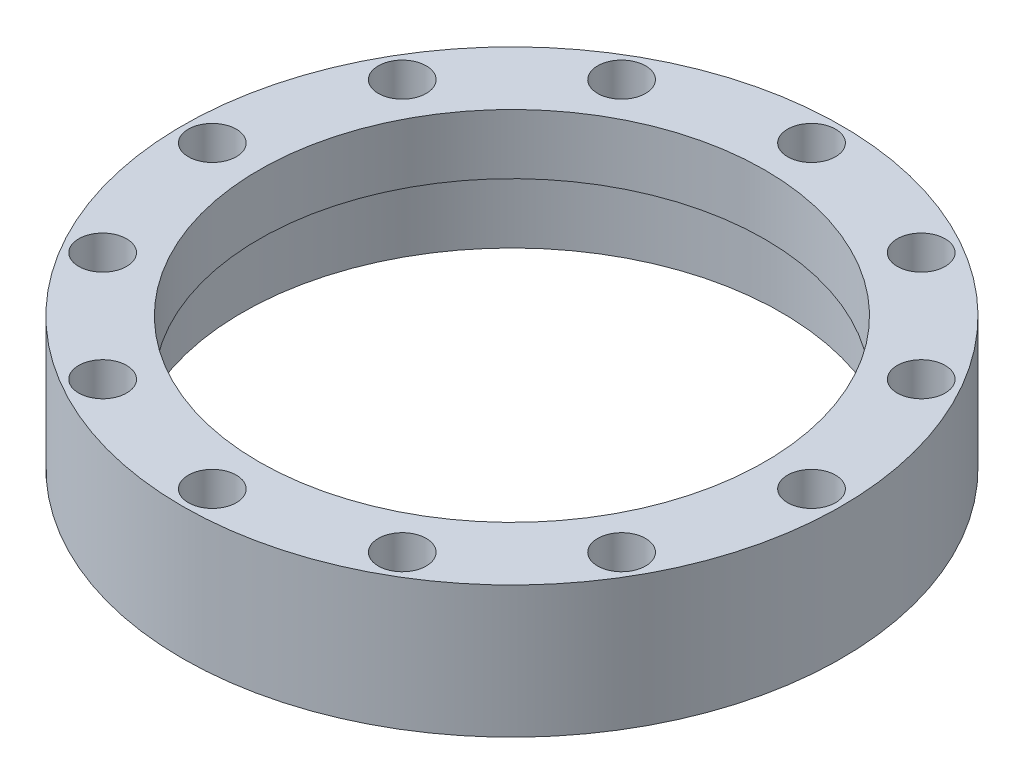
from build123d import *

# Parameters (mm, degrees)
SKETCH1_R           = 27.5
SKETCH1_R_2         = 22.5
SKETCH1_R_3         = 1.6
BOSS_EXTRUDE1_DEPTH = 11
SKETCH2_R           = 22.5
SKETCH2_R_2         = 21.1
BOSS_EXTRUDE2_DEPTH = 5
SKETCH3_R           = 2
CUT_EXTRUDE1_DEPTH  = 5


with BuildPart() as part:
    # Sketch1 → Boss-Extrude1 (new body)
    with BuildSketch(Plane(origin=(0, 0, 0), x_dir=(1, 0, 0), z_dir=(0, 1, 0))):
        Circle(SKETCH1_R)
        Circle(SKETCH1_R_2, mode=Mode.SUBTRACT)
        with Locations((0, 25)):
            Circle(SKETCH1_R_3, mode=Mode.SUBTRACT)
        with Locations((12.5, 21.650635095)):
            Circle(SKETCH1_R_3, mode=Mode.SUBTRACT)
        with Locations((21.650635095, 12.5)):
            Circle(SKETCH1_R_3, mode=Mode.SUBTRACT)
        with Locations((25, 0)):
            Circle(SKETCH1_R_3, mode=Mode.SUBTRACT)
        with Locations((21.650635095, -12.5)):
            Circle(SKETCH1_R_3, mode=Mode.SUBTRACT)
        with Locations((12.5, -21.650635095)):
            Circle(SKETCH1_R_3, mode=Mode.SUBTRACT)
        with Locations((0, -25)):
            Circle(SKETCH1_R_3, mode=Mode.SUBTRACT)
        with Locations((-12.5, -21.650635095)):
            Circle(SKETCH1_R_3, mode=Mode.SUBTRACT)
        with Locations((-21.650635095, -12.5)):
            Circle(SKETCH1_R_3, mode=Mode.SUBTRACT)
        with Locations((-25, 0)):
            Circle(SKETCH1_R_3, mode=Mode.SUBTRACT)
        with Locations((-21.650635095, 12.5)):
            Circle(SKETCH1_R_3, mode=Mode.SUBTRACT)
        with Locations((-12.5, 21.650635095)):
            Circle(SKETCH1_R_3, mode=Mode.SUBTRACT)
    extrude(amount=BOSS_EXTRUDE1_DEPTH)

    # Sketch2 → Boss-Extrude2 (add)
    with BuildSketch(Plane(origin=(0, 11, 0), x_dir=(1, 0, 0), z_dir=(0, 1, 0))):
        Circle(SKETCH2_R)
        Circle(SKETCH2_R_2, mode=Mode.SUBTRACT)
    extrude(amount=-BOSS_EXTRUDE2_DEPTH)

    # Sketch3 → Cut-Extrude1 (cut)
    with BuildSketch(Plane(origin=(0, 11, 0), x_dir=(1, 0, 0), z_dir=(0, 1, 0))):
        with Locations((0, 25)):
            Circle(SKETCH3_R)
        with Locations((12.5, 21.650635095)):
            Circle(SKETCH3_R)
        with Locations((21.650635095, 12.5)):
            Circle(SKETCH3_R)
        with Locations((25, 0)):
            Circle(SKETCH3_R)
        with Locations((21.650635095, -12.5)):
            Circle(SKETCH3_R)
        with Locations((12.5, -21.650635095)):
            Circle(SKETCH3_R)
        with Locations((0, -25)):
            Circle(SKETCH3_R)
        with Locations((-12.5, -21.650635095)):
            Circle(SKETCH3_R)
        with Locations((-21.650635095, -12.5)):
            Circle(SKETCH3_R)
        with Locations((-25, 0)):
            Circle(SKETCH3_R)
        with Locations((-21.650635095, 12.5)):
            Circle(SKETCH3_R)
        with Locations((-12.5, 21.650635095)):
            Circle(SKETCH3_R)
    extrude(amount=-CUT_EXTRUDE1_DEPTH, mode=Mode.SUBTRACT)


solid = part.part
